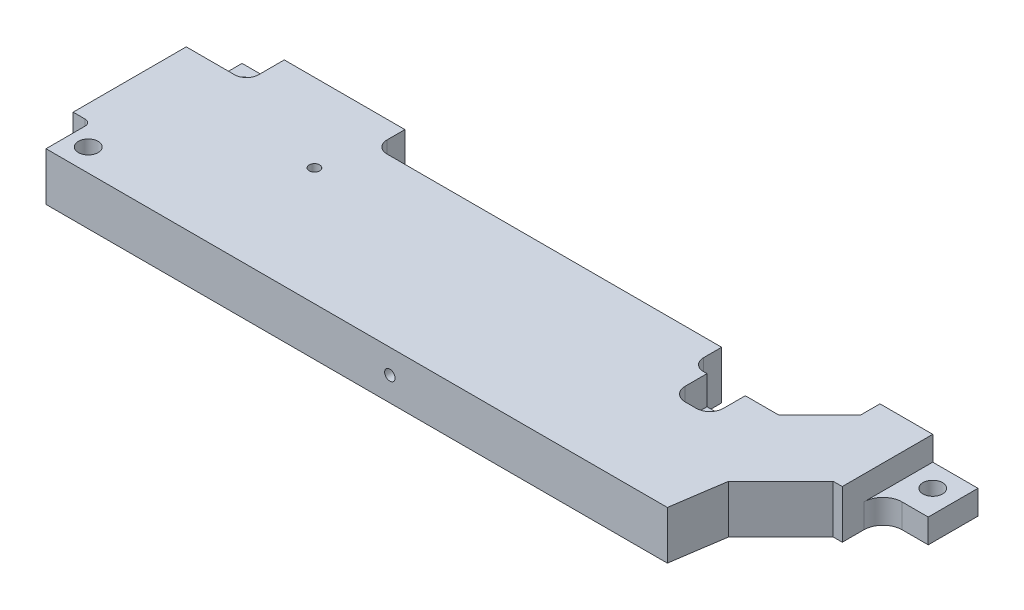
from build123d import *

# Parameters (mm, degrees)
SKETCH1_W                          = 250
SKETCH1_H                          = 16
BASE_EXTRUDE_DEPTH                 = 65
ACCESS_START                       = -16
ACCESS_FOR_BLADE_CLAMP_BOLTS_DEPTH = 16
CUT_EXTRUDE2_DEPTH                 = 17
CUT_EXTRUDE3_DEPTH                 = 17
F_1_4_CLEARANCE_HOLE1_D            = 6.5278
CUT_EXTRUDE4_DEPTH                 = 17
CUT_EXTRUDE5_DEPTH                 = 8
F_8_32_TAPPED_HOLE1_D              = 3.4544
F_8_32_TAPPED_HOLE2_D              = 3.4544
F_8_32_TAPPED_HOLE2_DEPTH          = 12.2936
F_8_32_TAPPED_HOLE2_TIP            = 1.037806461
F_8_32_TAPPED_HOLE3_D              = 3.4544
SKETCH20_W                         = 15
SKETCH20_H                         = 30
CUT_EXTRUDE6_DEPTH                 = 8
SKETCH22_W                         = 12.7
SKETCH22_H                         = 11.75
CUT_EXTRUDE8_DEPTH                 = 9.525
CUT_EXTRUDE9_DEPTH                 = 9
FILLET1_R                          = 4.5


with BuildPart() as part:
    # Sketch1 → Base-Extrude (new body)
    with BuildSketch(Plane.XY):
        with Locations((125, 0)):
            Rectangle(SKETCH1_W, SKETCH1_H)
    extrude(amount=BASE_EXTRUDE_DEPTH)

    # Sketch3 → Access for Blade Clamp Bolts (cut)
    with BuildSketch(Plane(origin=(0, 8, 0), x_dir=(-1, 0, 0), z_dir=(0, 1, 0)).offset(ACCESS_START)):
        Polygon((-764.876222455, 30), (-250, 30), (-232, 30), (-214.635668285, 47.364331715), (-212, 65), (-135.896448754, 574.220751675), (-809.679729524, 1352.941618451), (-1438.659503225, 808.720866775), align=None)
    extrude(amount=ACCESS_FOR_BLADE_CLAMP_BOLTS_DEPTH, mode=Mode.SUBTRACT)

    # Sketch6 → Cut-Extrude2 (cut, through all)
    with BuildSketch(Plane(origin=(0, 8, 0), x_dir=(-1, 0, 0), z_dir=(0, 1, 0))):
        with BuildLine():
            Line((-60, 0), (-110, 0))
            Line((-110, 0), (-110, 10))
            Line((-110, 10), (-64, 10))
            ThreePointArc((-64, 10), (-61.171572875, 8.828427125), (-60, 6))
            Line((-60, 6), (-60, 0))
        make_face()
        with BuildLine():
            Line((110, 0), (110, 6))
            ThreePointArc((110, 6), (108.828427125, 8.828427125), (106, 10))
            Line((106, 10), (64, 10))
            ThreePointArc((64, 10), (61.171572875, 8.828427125), (60, 6))
            Line((60, 6), (60, 0))
            Line((60, 0), (110, 0))
        make_face()
    extrude(amount=-CUT_EXTRUDE2_DEPTH, mode=Mode.SUBTRACT)

    # Sketch7 → Cut-Extrude3 (cut, through all)
    with BuildSketch(Plane(origin=(0, 8, 0), x_dir=(-1, 0, 0), z_dir=(0, 1, 0))):
        with BuildLine():
            Line((-217.5, 0), (-110, 0))
            Line((-110, 0), (-110, 10))
            Line((-110, 10), (-175, 10))
            Line((-175, 10), (-175, 16))
            ThreePointArc((-175, 16), (-176.171572875, 18.828427125), (-179, 20))
            Line((-179, 20), (-204, 20))
            Line((-204, 20), (-217.5, 6.5))
            Line((-217.5, 6.5), (-217.5, 5))
            Line((-217.5, 5), (-217.5, 0))
        make_face()
    extrude(amount=-CUT_EXTRUDE3_DEPTH, mode=Mode.SUBTRACT)

    # 1/4 Clearance Hole1 (through all)
    with Locations(Plane(origin=(242.5, 8, 22.5), x_dir=(0, 0, 1), z_dir=(0, 1, 0))):
        with Locations((0, 0), (35, -230), (-16.5, -230), (-15, 0)):
            Hole(F_1_4_CLEARANCE_HOLE1_D / 2)

    # Sketch11 → Cut-Extrude4 (cut, through all)
    with BuildSketch(Plane(origin=(0, 8, 0), x_dir=(-1, 0, 0), z_dir=(0, 1, 0))):
        with BuildLine():
            Line((0, 65), (0, 50))
            Line((0, 50), (-4, 50))
            ThreePointArc((-4, 50), (-5.414213562, 50.585786438), (-6, 52))
            Line((-6, 52), (-6, 65))
            Line((-6, 65), (0, 65))
        make_face()
        with BuildLine():
            Line((0, 0), (-6, 0))
            Line((-6, 0), (-6, 10.5))
            ThreePointArc((-6, 10.5), (-5.414213562, 11.914213562), (-4, 12.5))
            Line((-4, 12.5), (0, 12.5))
            Line((0, 12.5), (0, 0))
        make_face()
    extrude(amount=-CUT_EXTRUDE4_DEPTH, mode=Mode.SUBTRACT)

    # Sketch12 → Cut-Extrude5 (cut)
    with BuildSketch(Plane(origin=(0, 8, 0), x_dir=(-1, 0, 0), z_dir=(0, 1, 0))):
        with BuildLine():
            Line((0, 0), (-20, 0))
            Line((-20, 0), (-20, 8.5))
            ThreePointArc((-20, 8.5), (-18.828427125, 11.328427125), (-16, 12.5))
            Line((-16, 12.5), (0, 12.5))
            Line((0, 12.5), (0, 0))
        make_face()
    extrude(amount=-CUT_EXTRUDE5_DEPTH, mode=Mode.SUBTRACT)

    # #8-32 Tapped Hole1 (through all)
    with Locations(Plane(origin=(56, 8, 26), x_dir=(0, 0, 1), z_dir=(0, 1, 0))):
        with Locations((0, 0)):
            Hole(F_8_32_TAPPED_HOLE1_D / 2)

    # #8-32 Tapped Hole2
    with Locations(Plane.XY.offset(65)):
        with Locations((120, 0)):
            Hole(F_8_32_TAPPED_HOLE2_D / 2, depth=F_8_32_TAPPED_HOLE2_DEPTH)
            with Locations((0, 0, -(F_8_32_TAPPED_HOLE2_DEPTH + F_8_32_TAPPED_HOLE2_TIP / 2))):  # 118° drill point
                Cone(0, F_8_32_TAPPED_HOLE2_D / 2, F_8_32_TAPPED_HOLE2_TIP, mode=Mode.SUBTRACT)

    # #8-32 Tapped Hole3 (through all)
    with Locations(Plane(origin=(0, 8, 0), x_dir=(-1, 0, 0), z_dir=(0, 1, 0))):
        with Locations((-186.5, 26.9)):
            Hole(F_8_32_TAPPED_HOLE3_D / 2)

    # Sketch20 → Cut-Extrude6 (cut)
    with BuildSketch(Plane(origin=(0, 8, 0), x_dir=(-1, 0, 0), z_dir=(0, 1, 0))):
        with Locations((-242.5, 15)):
            Rectangle(SKETCH20_W, SKETCH20_H)
    extrude(amount=-CUT_EXTRUDE6_DEPTH, mode=Mode.SUBTRACT)

    # Sketch22 → Cut-Extrude8 (cut)
    with BuildSketch(Plane(origin=(0, 8, 0), x_dir=(-1, 0, 0), z_dir=(0, 1, 0))):
        with Locations((-186.5, 25.875)):
            Rectangle(SKETCH22_W, SKETCH22_H)
    extrude(amount=-CUT_EXTRUDE8_DEPTH, mode=Mode.SUBTRACT)

    # Sketch23 → Cut-Extrude9 (cut, through all)
    with BuildSketch(Plane(origin=(0, 0, 0), x_dir=(-1, 0, 0), z_dir=(0, 1, 0))):
        with BuildLine():
            Line((-241.35, 16.5), (-250, 16.5))
            Line((-250, 16.5), (-250, 30))
            Line((-250, 30), (-235, 30))
            Line((-235, 30), (-235, 22.85))
            ThreePointArc((-235, 22.85), (-236.859871939, 18.359871939), (-241.35, 16.5))
        make_face()
    extrude(amount=-CUT_EXTRUDE9_DEPTH, mode=Mode.SUBTRACT)

    # Fillet1
    fillet1_edges = [part.edges().sort_by_distance(p)[0] for p in [
        (180.15, 3.2375, 31.75),
        (192.85, 3.2375, 31.75),
    ]]
    fillet(fillet1_edges, radius=FILLET1_R)


solid = part.part
